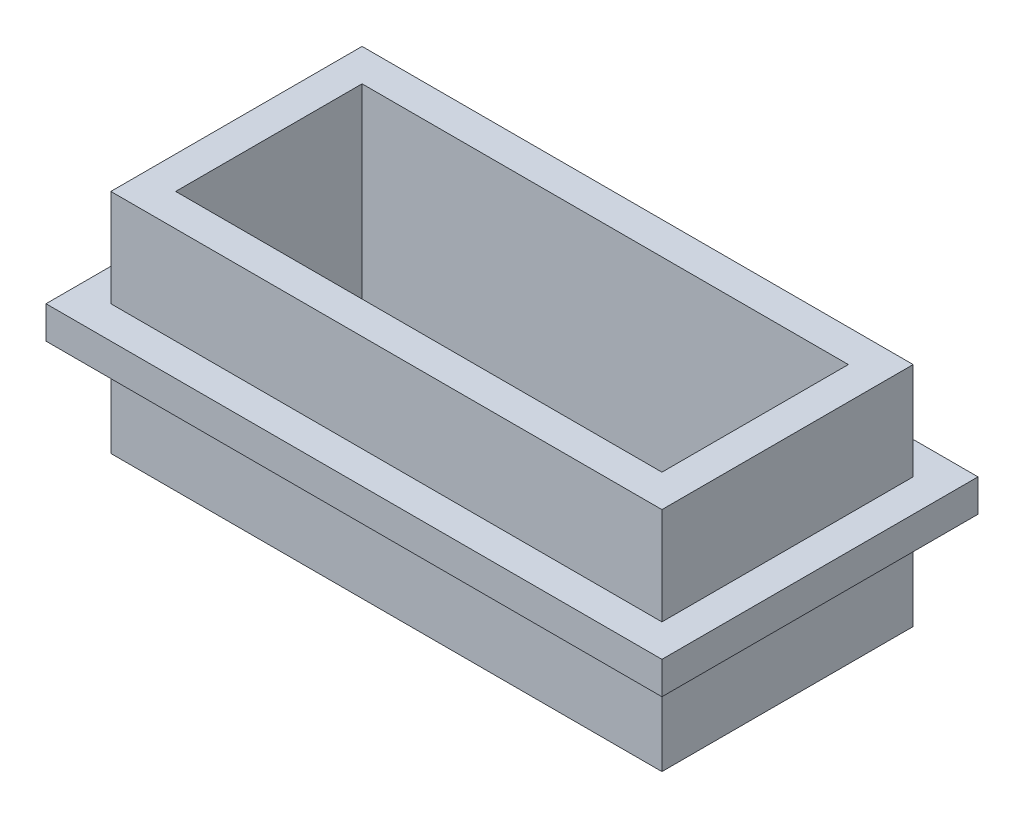
from build123d import *

# Parameters (mm, degrees)
SKETCH1_W           = 43.18
SKETCH1_H           = 19.685
SKETCH1_W_2         = 38.1
SKETCH1_H_2         = 14.605
BOSS_EXTRUDE1_DEPTH = 17.78
SKETCH2_W           = 48.26
SKETCH2_H           = 24.765
SKETCH2_W_2         = 38.1
SKETCH2_H_2         = 14.605
BOSS_EXTRUDE2_DEPTH = 2.54


with BuildPart() as part:
    # Sketch1 → Boss-Extrude1 (new body)
    with BuildSketch(Plane(origin=(0, 0, 0), x_dir=(1, 0, 0), z_dir=(0, 1, 0))):
        Rectangle(SKETCH1_W, SKETCH1_H)
        Rectangle(SKETCH1_W_2, SKETCH1_H_2, mode=Mode.SUBTRACT)
    extrude(amount=BOSS_EXTRUDE1_DEPTH)

    # Sketch2 → Boss-Extrude2 (add)
    with BuildSketch(Plane(origin=(0, 7.62, 0), x_dir=(1, 0, 0), z_dir=(0, 1, 0))):
        Rectangle(SKETCH2_W, SKETCH2_H)
        Rectangle(SKETCH2_W_2, SKETCH2_H_2, mode=Mode.SUBTRACT)
    extrude(amount=BOSS_EXTRUDE2_DEPTH)


solid = part.part
